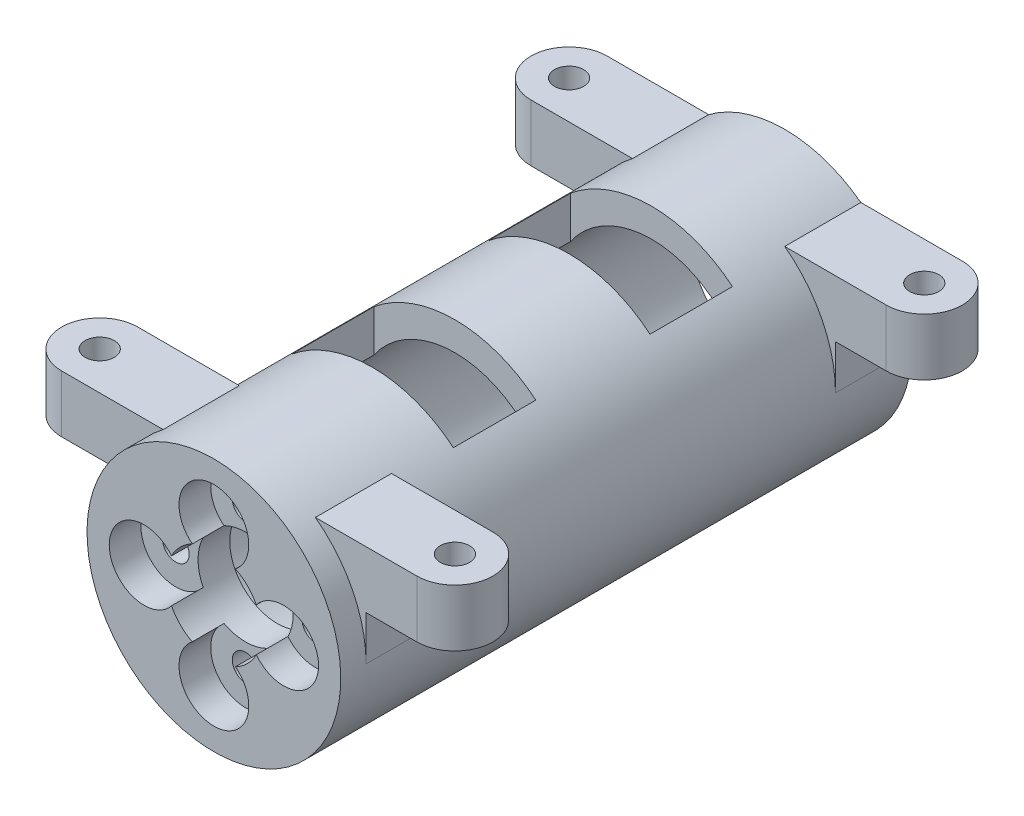
from build123d import *

# Parameters (mm, degrees)
SKIZZE6_R                            = 1.05
SCHNITT_LINEAR_AUSTRAGEN3_DEPTH      = 46
SKIZZE7_R                            = 2.75
SCHNITT_LINEAR_AUSTRAGEN4_DEPTH      = 2.5
AUFSATZ_LINEAR_START                 = -2
AUFSATZ_LINEAR_AUSTRAGEN6_DEPTH      = 6
AUFSATZ_LINEAR_AUSTRAGEN7_DEPTH      = 4.5
SKIZZE14_R                           = 1.15
SCHNITT_LINEAR_AUSTRAGEN5_DEPTH      = 7.5
SKIZZE17_W                           = 6.5
SKIZZE17_H                           = 2.4
SCHNITT_LINEAR_AUSTRAGEN9_DEPTH      = 18
SCHNITT_LINEAR_AUSTRAGEN9_DEPTH_BACK = 18
SCHNITT_LINEAR_START                 = -3.300852
SKIZZE18_W                           = 12.760877712
SKIZZE18_H                           = 6.5
SCHNITT_LINEAR_AUSTRAGEN10_DEPTH     = 3.300852
SKIZZE19_R                           = 3.75
SCHNITT_LINEAR_AUSTRAGEN11_DEPTH     = 6


with BuildPart() as part:
    # Skizze5 → Rotation1 (revolve)
    with BuildSketch(Plane(origin=(0, 0, 0), x_dir=(0, 0, -1), z_dir=(1, 0, 0))):
        Polygon((40, 7.75), (0, 7.75), (0, 3.75), (-1, 3.75), (-1, 3.25), (-2.6, 3.25), (-2.6, 2), (-5, 2), (-5, 10), (40, 10), align=None)
    revolve(axis=Axis((0, 0, 0), (0, 0, 1)))

    # Skizze6 → Schnitt-Linear austragen3 (cut, through all)
    with BuildSketch(Plane.XY.offset(5)):
        with Locations((0, 5.5)):
            Circle(SKIZZE6_R)
        with Locations((0, -5.5)):
            Circle(SKIZZE6_R)
        with Locations((5.5, 0)):
            Circle(SKIZZE6_R)
        with Locations((-5.5, 0)):
            Circle(SKIZZE6_R)
    extrude(amount=-SCHNITT_LINEAR_AUSTRAGEN3_DEPTH, mode=Mode.SUBTRACT)

    # Skizze7 → Schnitt-Linear austragen4 (cut)
    with BuildSketch(Plane.XY.offset(5)):
        with Locations((0, 5.5)):
            Circle(SKIZZE7_R)
        with Locations((0, -5.5)):
            Circle(SKIZZE7_R)
        with Locations((5.5, 0)):
            Circle(SKIZZE7_R)
        with Locations((-5.5, 0)):
            Circle(SKIZZE7_R)
    extrude(amount=-SCHNITT_LINEAR_AUSTRAGEN4_DEPTH, mode=Mode.SUBTRACT)

    # Skizze12 → Aufsatz-Linear austragen6 (add)
    with BuildSketch(Plane.XY.offset(5).offset(AUFSATZ_LINEAR_START)):
        with BuildLine():
            Line((-10, 0), (-10, 8))
            Line((-10, 8), (-6, 8))
            ThreePointArc((-6, 8), (-8.94427191, 4.472135955), (-10, 0))
        make_face()
        with BuildLine():
            Line((10, 8), (6, 8))
            ThreePointArc((6, 8), (8.94427191, 4.472135955), (10, 0))
            Line((10, 0), (10, 8))
        make_face()
    aufsatz_linear_austragen6 = extrude(amount=-AUFSATZ_LINEAR_AUSTRAGEN6_DEPTH)

    # Spiegeln1: Aufsatz-Linear austragen6 across plane
    add(aufsatz_linear_austragen6.mirror(Plane(origin=(0, 0, -18.5), x_dir=(1, 0, 0), z_dir=(0, 0, -1))))

    # Skizze13 → Aufsatz-Linear austragen7 (add)
    with BuildSketch(Plane(origin=(0, 8, 0), x_dir=(1, 0, 0), z_dir=(0, 1, 0))):
        with BuildLine():
            Line((-14, 40), (-10, 40))
            Line((-10, 40), (-10, 34))
            Line((-10, 34), (-14, 34))
            ThreePointArc((-14, 34), (-17, 37), (-14, 40))
        make_face()
        with BuildLine():
            Line((14, 34), (10, 34))
            Line((10, 34), (10, 40))
            Line((10, 40), (14, 40))
            ThreePointArc((14, 40), (17, 37), (14, 34))
        make_face()
        with BuildLine():
            Line((14, -3), (10, -3))
            Line((10, -3), (10, 3))
            Line((10, 3), (14, 3))
            ThreePointArc((14, 3), (17, 0), (14, -3))
        make_face()
        with BuildLine():
            Line((-14, 3), (-10, 3))
            Line((-10, 3), (-10, -3))
            Line((-10, -3), (-14, -3))
            ThreePointArc((-14, -3), (-17, 0), (-14, 3))
        make_face()
    extrude(amount=-AUFSATZ_LINEAR_AUSTRAGEN7_DEPTH)

    # Skizze14 → Schnitt-Linear austragen5 (cut, through all)
    with BuildSketch(Plane(origin=(0, 3.5, 0), x_dir=(-1, 0, 0), z_dir=(0, -1, 0))):
        with Locations((14, 0)):
            Circle(SKIZZE14_R)
        with Locations((-14, 0)):
            Circle(SKIZZE14_R)
        with Locations((-14, 37)):
            Circle(SKIZZE14_R)
        with Locations((14, 37)):
            Circle(SKIZZE14_R)
    extrude(amount=-SCHNITT_LINEAR_AUSTRAGEN5_DEPTH, mode=Mode.SUBTRACT)

    # Skizze17 → Schnitt-Linear austragen9 (cut, two sides)
    with BuildSketch(Plane(origin=(0, 0, 0), x_dir=(0, 0, -1), z_dir=(1, 0, 0))) as schnitt_linear_austragen9_sk:
        with Locations((10.75, 8.9)):
            Rectangle(SKIZZE17_W, SKIZZE17_H)
        with Locations((26.25, 8.9)):
            Rectangle(SKIZZE17_W, SKIZZE17_H)
    extrude(amount=SCHNITT_LINEAR_AUSTRAGEN9_DEPTH, mode=Mode.SUBTRACT)
    extrude(schnitt_linear_austragen9_sk.sketch, amount=-SCHNITT_LINEAR_AUSTRAGEN9_DEPTH_BACK, mode=Mode.SUBTRACT)

    # Skizze18 → Schnitt-Linear austragen10 (cut)
    with BuildSketch(Plane(origin=(0, 7.7, 0), x_dir=(1, 0, 0), z_dir=(0, 1, 0)).offset(SCHNITT_LINEAR_START)):
        with Locations((0, 10.75)):
            Rectangle(SKIZZE18_W, SKIZZE18_H)
        with Locations((0, 26.25)):
            Rectangle(SKIZZE18_W, SKIZZE18_H)
    extrude(amount=SCHNITT_LINEAR_AUSTRAGEN10_DEPTH, mode=Mode.SUBTRACT)

    # Skizze19 → Schnitt-Linear austragen11 (cut, through all)
    with BuildSketch(Plane(origin=(0, 0, 0), x_dir=(-1, 0, 0), z_dir=(0, 0, -1))):
        Circle(SKIZZE19_R)
    extrude(amount=-SCHNITT_LINEAR_AUSTRAGEN11_DEPTH, mode=Mode.SUBTRACT)


solid = part.part
